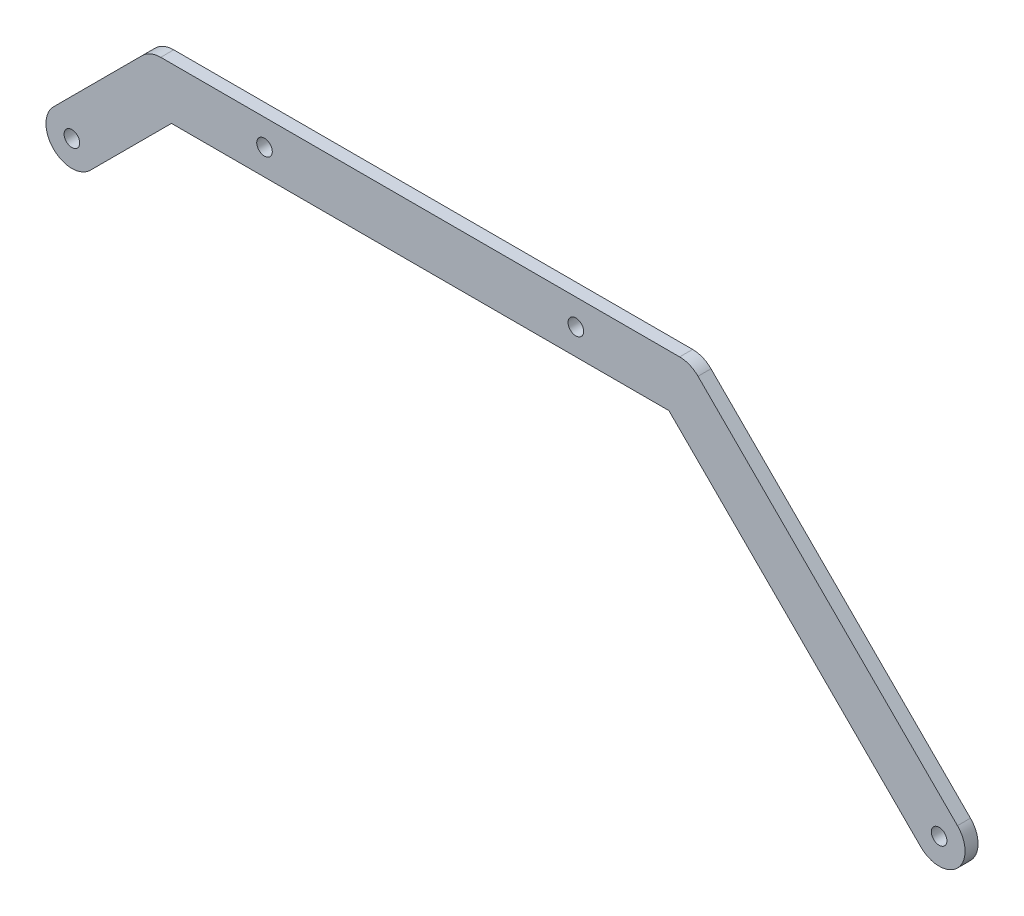
from build123d import *

# Parameters (mm, degrees)
SKETCH1_R           = 3
BOSS_EXTRUDE2_DEPTH = 5


with BuildPart() as part:
    # Sketch1 → Boss-Extrude2 (new body)
    with BuildSketch(Plane.XY):
        with BuildLine():
            Line((-195.857864376, -10), (-227.161878591, -41.304014214))
            ThreePointArc((-227.161878591, -41.304014214), (-241.304014214, -41.304014214), (-241.304014214, -27.161878591))
            Line((-241.304014214, -27.161878591), (-207.071067812, 7.071067812))
            ThreePointArc((-207.071067812, 7.071067812), (-203.826834324, 9.238795325), (-200, 10))
            Line((-200, 10), (0, 10))
            ThreePointArc((0, 10), (3.826834324, 9.238795325), (7.071067812, 7.071067812))
            Line((7.071067812, 7.071067812), (107.071067812, -92.928932188))
            ThreePointArc((107.071067812, -92.928932188), (107.071067812, -107.071067812), (92.928932188, -107.071067812))
            Line((92.928932188, -107.071067812), (-4.142135624, -10))
            Line((-4.142135624, -10), (-195.857864376, -10))
        make_face()
        with Locations((-234.232946402, -34.232946402)):
            Circle(SKETCH1_R, mode=Mode.SUBTRACT)
        with Locations((100, -100)):
            Circle(SKETCH1_R, mode=Mode.SUBTRACT)
        with Locations((-160, 0)):
            Circle(SKETCH1_R, mode=Mode.SUBTRACT)
        with Locations((-40, 0)):
            Circle(SKETCH1_R, mode=Mode.SUBTRACT)
    extrude(amount=BOSS_EXTRUDE2_DEPTH)


solid = part.part
